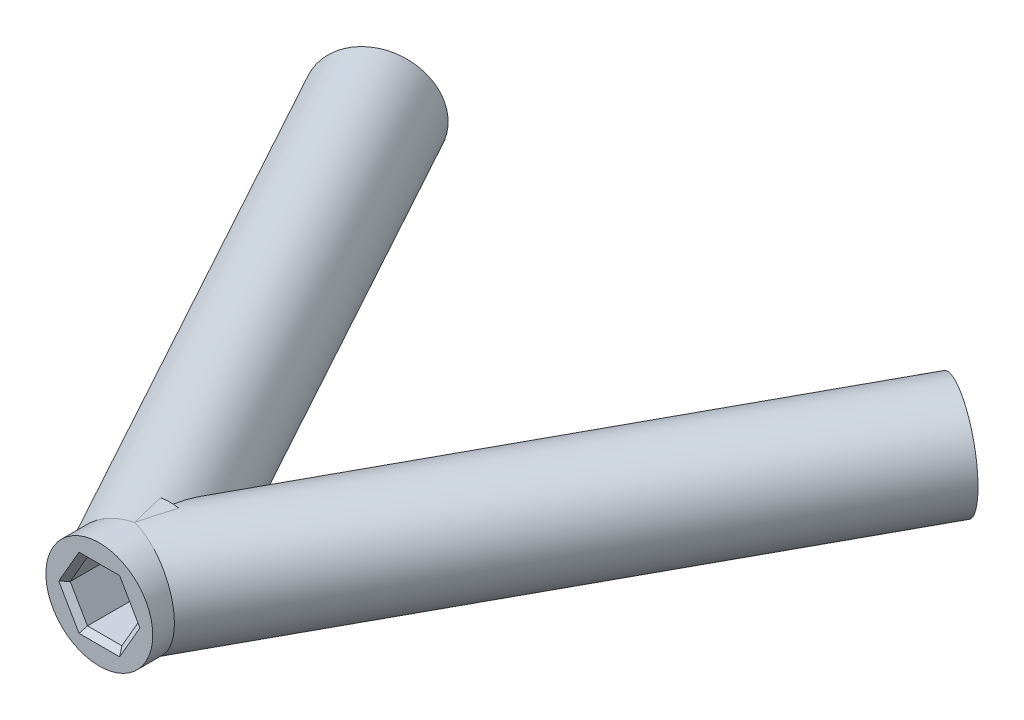
from build123d import *

# Parameters (mm, degrees)
SKETCH1_W          = 5
SKETCH1_H          = 6.6
CUT_EXTRUDE2_DEPTH = 6.6
CUT_EXTRUDE3_DEPTH = 6.6
CUT_EXTRUDE4_DEPTH = 6.6
CHAMFER1_SIZE      = 0.5


with BuildPart() as part:
    # Sketch1 → Revolve-Thin1 (revolve)
    with BuildSketch(Plane(origin=(0, 0, 0), x_dir=(1, 0, 0), z_dir=(0, 1, 0))):
        with Locations((-2.5, 20.8)):
            Rectangle(SKETCH1_W, SKETCH1_H)
    revolve(axis=Axis((0, 0, 0), (0, 0, -1)))

    # Sketch3 → Revolve-Thin4 (revolve)
    with BuildSketch(Plane(origin=(0, 0, 0), x_dir=(1, 0, 0), z_dir=(0, 1, 0))):
        Polygon((-27.192355447, 70.553826822), (0, 20.8), (4.387478051, 23.197923342), (-22.804877396, 72.951750164), align=None)
    revolve(axis=Axis((-27.192355447, 0, -70.553826822), (0.479584668, 0, 0.87749561)))

    # Sketch4 → Revolve-Thin3 (revolve)
    with BuildSketch(Plane(origin=(0, 0, 0), x_dir=(1, 0, 0), z_dir=(0, 1, 0))):
        Polygon((0, 20.8), (27.192355447, 70.553826822), (22.804877396, 72.951750164), (-4.387478051, 23.197923342), align=None)
    revolve(axis=Axis((0, 0, -20.8), (0.479584668, 0, -0.87749561)))

    # Sketch6 → Cut-Extrude2 (cut)
    with BuildSketch(Plane.XY.offset(-17.5)):
        Polygon((1.610807251, 2.79), (-1.610807251, 2.79), (-3.221614502, 0), (-1.610807251, -2.79), (1.610807251, -2.79), (3.221614502, 0), align=None)
    extrude(amount=-CUT_EXTRUDE2_DEPTH, mode=Mode.SUBTRACT)

    # Sketch7 → Cut-Extrude3 (cut)
    with BuildSketch(Plane(origin=(35.945691024, 0, -65.769796576), x_dir=(-0.87749561, 0, -0.479584668), z_dir=(0.479584668, 0, -0.87749561))):
        Polygon((7.021637489, 1.286202481), (7.384615273, -1.914898444), (10.338338885, -3.201100925), (12.929084714, -1.286202481), (12.566106931, 1.914898444), (9.612383318, 3.201100925), align=None)
    extrude(amount=-CUT_EXTRUDE3_DEPTH, mode=Mode.SUBTRACT)

    # Sketch8 → Cut-Extrude4 (cut)
    with BuildSketch(Plane(origin=(-35.945691024, 0, -65.769796576), x_dir=(-0.87749561, 0, 0.479584668), z_dir=(-0.479584668, 0, -0.87749561))):
        Polygon((-9.612383318, 3.201100925), (-12.566106931, 1.914898444), (-12.929084714, -1.286202481), (-10.338338885, -3.201100925), (-7.384615273, -1.914898444), (-7.021637489, 1.286202481), align=None)
    extrude(amount=-CUT_EXTRUDE4_DEPTH, mode=Mode.SUBTRACT)

    # Chamfer1
    chamfer1_edges = [part.edges().sort_by_distance(p)[0] for p in [
        (2.416210877, 1.395, -17.5),
        (0, 2.79, -17.5),
        (-2.416210877, 1.395, -17.5),
        (-2.416210877, -1.395, -17.5),
        (0, -2.79, -17.5),
        (2.416210877, -1.395, -17.5),
        (28.647550905, 2.243651703, -69.758507252),
        (29.624979245, -0.314347981, -69.224305553),
        (28.169783788, -2.557999684, -70.019625122),
        (25.73715999, -2.243651703, -71.349146391),
        (24.75973165, 0.314347981, -71.883348091),
        (26.214927107, 2.557999684, -71.088028522),
        (-28.647550905, 2.243651703, -69.758507252),
        (-26.214927107, 2.557999684, -71.088028522),
        (-24.75973165, 0.314347981, -71.883348091),
        (-25.73715999, -2.243651703, -71.349146391),
        (-28.169783788, -2.557999684, -70.019625122),
        (-29.624979245, -0.314347981, -69.224305553),
    ]]
    chamfer(chamfer1_edges, length=CHAMFER1_SIZE)


solid = part.part
